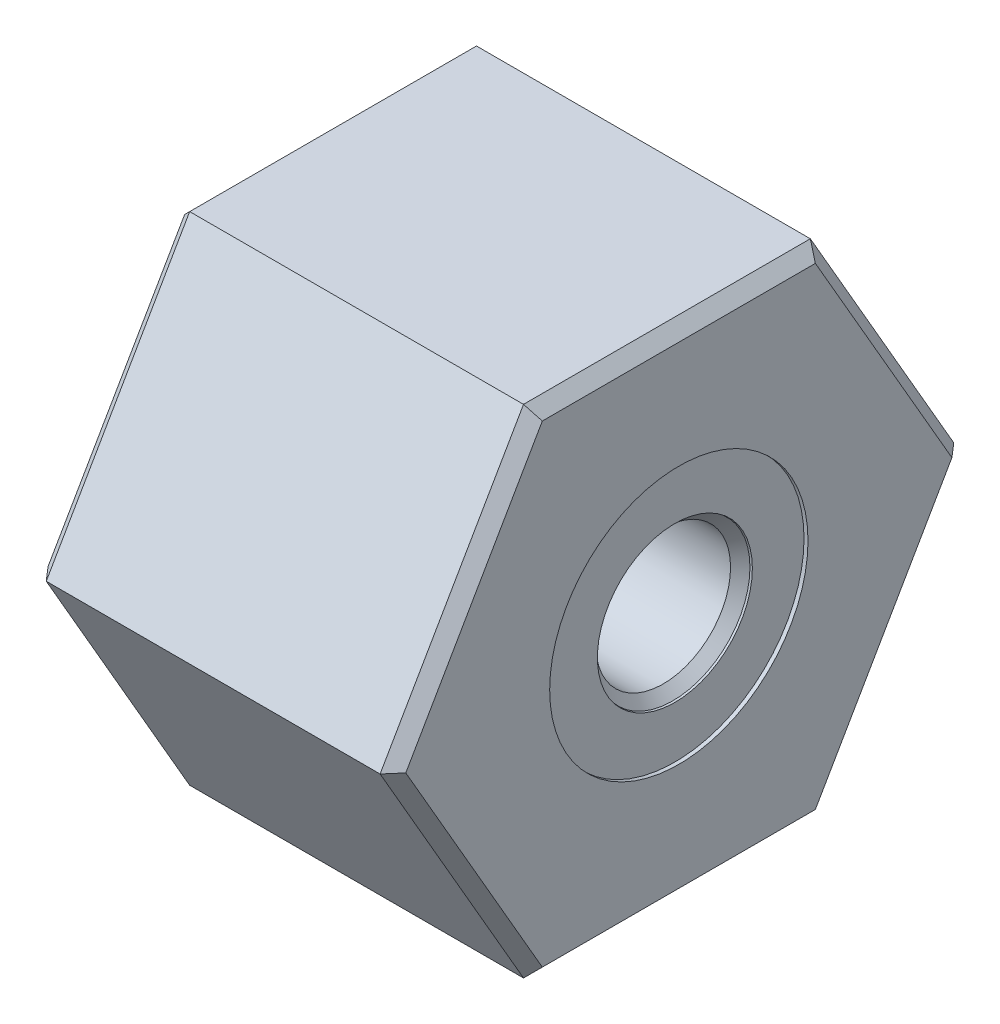
from build123d import *

# Parameters (mm, degrees)
EXTRUDE1_DEPTH = 22.86
CHAMFER1_SIZE  = 0.254
CHAMFER3_SIZE  = 0.762
CHAMFER4_SIZE  = 0.762
FILLET1_R      = 0.508


with BuildPart() as part:
    # Sketch1 → Extrude1 (new body)
    with BuildSketch(Plane(origin=(0, 0, 0), x_dir=(0, 0, -1), z_dir=(1, 0, 0))):
        Polygon((9.165435523, 15.875), (-9.165435523, 15.875), (-18.330871047, 0), (-9.165435523, -15.875), (9.165435523, -15.875), (18.330871047, 0), align=None)
    extrude(amount=EXTRUDE1_DEPTH)

    # Sketch2 → Cut-Revolve1 (revolve, cut)
    with BuildSketch(Plane.XY, mode=Mode.PRIVATE) as cut_revolve1_sk:
        Polygon((0, 12.2555), (0, 0), (22.86, 0), (22.86, 8.255), (22.606, 8.255), (22.606, 4.953), (22.479, 4.926005317), (21.858294683, 4.3053), (15.24, 4.3053), (14.478, 5.0673), (14.478, 11.7221), (10.16, 11.7221), (10.16, 12.2555), align=None)
    revolve(cut_revolve1_sk.sketch.rotate(Axis((0, 0, 0), (1, 0, 0)), 270), axis=Axis((0, 0, 0), (1, 0, 0)), mode=Mode.SUBTRACT)  # turned: the seam where the file's is

    # Chamfer1
    chamfer1_edges = [part.edges().sort_by_distance(p)[0] for p in [
        (0, 0, 12.2555),
    ]]
    chamfer(chamfer1_edges, length=CHAMFER1_SIZE)

    # Chamfer3
    chamfer3_edges = [part.edges().sort_by_distance(p)[0] for p in [
        (0, -7.9375, -13.748153285),
        (0, -15.875, 0),
        (0, -7.9375, 13.748153285),
        (0, 7.9375, 13.748153285),
        (0, 15.875, 0),
        (0, 7.9375, -13.748153285),
    ]]
    chamfer(chamfer3_edges, length=CHAMFER3_SIZE)

    # Chamfer4
    chamfer4_edges = [part.edges().sort_by_distance(p)[0] for p in [
        (22.86, 7.9375, 13.748153285),
        (22.86, -7.9375, 13.748153285),
        (22.86, -15.875, 0),
        (22.86, -7.9375, -13.748153285),
        (22.86, 7.9375, -13.748153285),
        (22.86, 15.875, 0),
    ]]
    chamfer(chamfer4_edges, length=CHAMFER4_SIZE)

    # Fillet1
    fillet1_edges = [part.edges().sort_by_distance(p)[0] for p in [
        (10.16, 0, 12.2555),
    ]]
    fillet(fillet1_edges, radius=FILLET1_R)


solid = part.part
